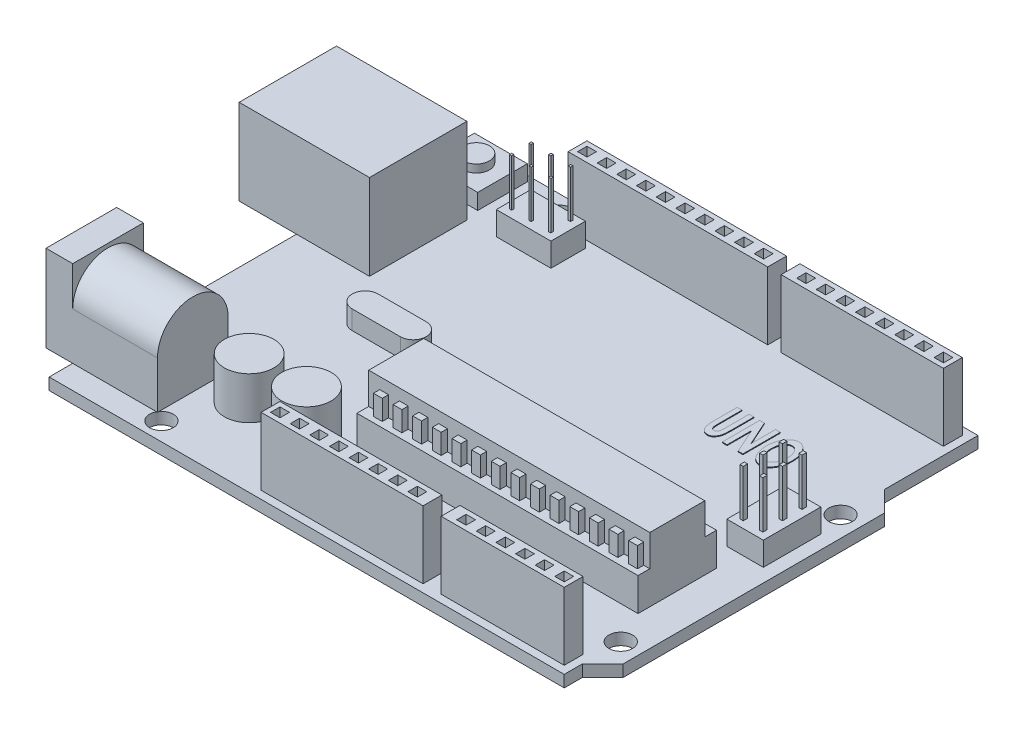
from build123d import *

# Parameters (mm, degrees)
SKETCH_1_R                  = 1.5
EXTRUDE_1_DEPTH             = 1.5
SKETCH_2_W                  = 16.6
SKETCH_2_H                  = 12.4
EXTRUDE_2_DEPTH             = 10.9
SKETCH_3_W                  = 4.372856204
SKETCH_3_H                  = 2.036672752
CUT_EXTRUDE_1_DEPTH         = 10.9
SKETCH_4_W                  = 6.743789425
SKETCH_4_H                  = 6.323115379
EXTRUDE_3_DEPTH             = 2
SKETCH_5_R                  = 1.664601264
EXTRUDE_4_DEPTH             = 1
SKETCH_6_W                  = 47.8
SKETCH_6_H                  = 2.4
SKETCH_6_W_2                = 38.6
EXTRUDE_5_DEPTH             = 8.6
SKETCH_7_W                  = 35.8
SKETCH_7_H                  = 10
EXTRUDE_6_DEPTH             = 8.2
SKETCH_8_R                  = 3.15
EXTRUDE_7_DEPTH             = 5.4
SKETCH_9_W                  = 1.2
SKETCH_9_H                  = 1.2
CUT_EXTRUDE_2_DEPTH         = 5.4
PATTERN_LINEAR_1_COUNT      = 8
PATTERN_LINEAR_1_PITCH      = 2.5
SKETCH_10_W                 = 1.2
SKETCH_10_H                 = 1.2
CUT_EXTRUDE_3_DEPTH         = 5.4
PATTERN_LINEAR_2_COUNT      = 10
PATTERN_LINEAR_2_PITCH      = 2.5
SKETCH_11_W                 = 1.2
SKETCH_11_H                 = 1.2
CUT_EXTRUDE_4_DEPTH         = 5.4
PATTERN_LINEAR_3_COUNT      = 6
PATTERN_LINEAR_3_PITCH      = 2.5
SKETCH_12_W                 = 1.2
SKETCH_12_H                 = 1.2
CUT_EXTRUDE_5_DEPTH         = 5.4
PATTERN_LINEAR_4_COUNT      = 8
PATTERN_LINEAR_4_PITCH      = 2.5
SKETCH_13_W                 = 9
SKETCH_13_H                 = 11
EXTRUDE_8_DEPTH             = 3.4
EXTRUDE_9_DEPTH             = 10.8
SKETCH_15_R                 = 3.884486149
SKETCH_15_R_2               = 0.407550436
CUT_EXTRUDE_6_DEPTH         = 10.8
SKETCH_16_W                 = 35.8
SKETCH_16_H                 = 1.5
CUT_EXTRUDE_7_DEPTH         = 4
SKETCH_17_W                 = 1.118511392
SKETCH_17_H                 = 2.561041253
EXTRUDE_10_DEPTH            = 0.8
PATTERN_LINEAR_5_COUNT      = 14
PATTERN_LINEAR_5_PITCH      = 2.5
SKETCH_18_W                 = 1.118511392
SKETCH_18_H                 = 2.561041253
EXTRUDE_11_DEPTH            = 0.8
PATTERN_LINEAR_6_COUNT      = 14
PATTERN_LINEAR_6_PITCH      = 2.5
SKETCH_19_W                 = 2.303918371
SKETCH_19_H                 = 2.4
SKETCH_19_W_2               = 1.705404008
CUT_EXTRUDE_8_DEPTH         = 8.6
SKETCH_20_W                 = 4.649103818
SKETCH_20_H                 = 7.318508938
SKETCH_20_W_2               = 6.955258845
SKETCH_20_H_2               = 4.390904447
EXTRUDE_12_DEPTH            = 3
SKETCH_21_W                 = 0.417659477
SKETCH_21_H                 = 0.556879301
EXTRUDE_13_DEPTH            = 6
PATTERN_LINEAR_7_COUNT      = 2
PATTERN_LINEAR_7_PITCH      = 2.5
PATTERN_LINEAR_7_COUNT_DIR2 = 3
PATTERN_LINEAR_7_PITCH_DIR2 = 2.5
SKETCH_22_W                 = 0.286309363
SKETCH_22_H                 = 0.308333161
EXTRUDE_14_DEPTH            = 6
PATTERN_LINEAR_8_COUNT      = 3
PATTERN_LINEAR_8_PITCH      = 2.5
PATTERN_LINEAR_8_COUNT_DIR2 = 2
PATTERN_LINEAR_8_PITCH_DIR2 = 2.5
CUT_EXTRUDE_9_DEPTH         = 3
EXTRUDE_15_DEPTH            = 0.1


with BuildPart() as part:
    # 草圖1 → 填料-伸長1 (new body)
    with BuildSketch(Plane(origin=(0, 0, 0), x_dir=(1, 0, 0), z_dir=(0, 1, 0))):
        Polygon((25.264109575, 24.624375052), (27.864109575, 22.024375052), (27.864109575, -11.275624948), (25.264109575, -13.875624948), (25.264109575, -16.175624948), (-40.335890425, -16.175624948), (-40.335890425, 36.524375052), (25.264109575, 36.524375052), align=None)
        with Locations((25.264109575, 19.024375052)):
            Circle(SKETCH_1_R, mode=Mode.SUBTRACT)
        with Locations((25.264109575, -8.975624948)):
            Circle(SKETCH_1_R, mode=Mode.SUBTRACT)
        with Locations((-25.735890425, 34.224375052)):
            Circle(SKETCH_1_R, mode=Mode.SUBTRACT)
        with Locations((-28.335890425, -13.875624948)):
            Circle(SKETCH_1_R, mode=Mode.SUBTRACT)
    extrude(amount=EXTRUDE_1_DEPTH)

    # 草圖2 → 填料-伸長2 (add)
    with BuildSketch(Plane(origin=(0, 1.5, 0), x_dir=(1, 0, 0), z_dir=(0, 1, 0))):
        with Locations((-39.335890425, 21.524375052)):
            Rectangle(SKETCH_2_W, SKETCH_2_H)
    extrude(amount=EXTRUDE_2_DEPTH)

    # 草圖3 → 除料-伸長1 (cut)
    with BuildSketch(Plane.ZY.offset(47.635890425)):
        Polygon((-24.401133252, 11.321632952), (-18.650527832, 11.321632952), (-16.40419759, 9.07530271), (-16.40419759, 2.815529102), (-26.677414564, 2.815529102), (-26.677414564, 9.07530271), align=None)
        with Locations((-21.555781612, 7.308189586)):
            Rectangle(SKETCH_3_W, SKETCH_3_H, mode=Mode.SUBTRACT)
    extrude(amount=-CUT_EXTRUDE_1_DEPTH, mode=Mode.SUBTRACT)

    # 草圖4 → 填料-伸長3 (add)
    with BuildSketch(Plane(origin=(0, 1.5, 0), x_dir=(1, 0, 0), z_dir=(0, 1, 0))):
        with Locations((-34.776113962, 32.636854406)):
            Rectangle(SKETCH_4_W, SKETCH_4_H)
    extrude(amount=EXTRUDE_3_DEPTH)

    # 草圖5 → 填料-伸長4 (add)
    with BuildSketch(Plane(origin=(0, 3.5, 0), x_dir=(1, 0, 0), z_dir=(0, 1, 0))):
        with Locations((-34.79753275, 32.69490015)):
            Circle(SKETCH_5_R)
    extrude(amount=EXTRUDE_4_DEPTH)

    # 草圖6 → 填料-伸長5 (add)
    with BuildSketch(Plane(origin=(0, 1.5, 0), x_dir=(1, 0, 0), z_dir=(0, 1, 0))):
        with Locations((0.364109575, 34.324375052)):
            Rectangle(SKETCH_6_W, SKETCH_6_H)
        with Locations((4.964109575, -13.975624948)):
            Rectangle(SKETCH_6_W_2, SKETCH_6_H)
    extrude(amount=EXTRUDE_5_DEPTH)

    # 草圖7 → 填料-伸長6 (add)
    with BuildSketch(Plane(origin=(0, 1.5, 0), x_dir=(1, 0, 0), z_dir=(0, 1, 0))):
        with Locations((5.364109575, 0.224375052)):
            Rectangle(SKETCH_7_W, SKETCH_7_H)
    extrude(amount=EXTRUDE_6_DEPTH)

    # 草圖8 → 填料-伸長7 (add)
    with BuildSketch(Plane(origin=(0, 1.5, 0), x_dir=(1, 0, 0), z_dir=(0, 1, 0))):
        with Locations((-24.77532315, -6.259782682)):
            Circle(SKETCH_8_R)
        with Locations((-17.480788386, -6.259782682)):
            Circle(SKETCH_8_R)
        with BuildLine():
            Line((-26.143940418, 11.529212552), (-20.017718682, 11.529212552))
            ThreePointArc((-20.017718682, 11.529212552), (-18.368351291, 9.879845161), (-20.017718682, 8.230477771))
            Line((-20.017718682, 8.230477771), (-26.143940418, 8.230477771))
            ThreePointArc((-26.143940418, 8.230477771), (-27.793307808, 9.879845161), (-26.143940418, 11.529212552))
        make_face()
    extrude(amount=EXTRUDE_7_DEPTH)

    # 草圖9 → 除料-伸長2 (cut)
    with BuildSketch(Plane(origin=(0, 10.1, 0), x_dir=(1, 0, 0), z_dir=(0, 1, 0))):
        with Locations((23.064109575, 34.324375052)):
            Rectangle(SKETCH_9_W, SKETCH_9_H)
    cut_extrude_2 = extrude(amount=-CUT_EXTRUDE_2_DEPTH, mode=Mode.SUBTRACT)

    # 直線複製排列1: 除料-伸長2 ×8
    with Locations(*[(-i * PATTERN_LINEAR_1_PITCH, 0, 0) for i in range(1, PATTERN_LINEAR_1_COUNT)]):
        add(cut_extrude_2, mode=Mode.SUBTRACT)

    # 草圖10 → 除料-伸長3 (cut)
    with BuildSketch(Plane(origin=(0, 10.1, 0), x_dir=(1, 0, 0), z_dir=(0, 1, 0))):
        with Locations((-22.335890425, 34.324375052)):
            Rectangle(SKETCH_10_W, SKETCH_10_H)
    cut_extrude_3 = extrude(amount=-CUT_EXTRUDE_3_DEPTH, mode=Mode.SUBTRACT)

    # 直線複製排列2: 除料-伸長3 ×10
    with Locations(*[(i * PATTERN_LINEAR_2_PITCH, 0, 0) for i in range(1, PATTERN_LINEAR_2_COUNT)]):
        add(cut_extrude_3, mode=Mode.SUBTRACT)

    # 草圖11 → 除料-伸長4 (cut)
    with BuildSketch(Plane(origin=(0, 10.1, 0), x_dir=(1, 0, 0), z_dir=(0, 1, 0))):
        with Locations((23.064109575, -13.975624948)):
            Rectangle(SKETCH_11_W, SKETCH_11_H)
    cut_extrude_4 = extrude(amount=-CUT_EXTRUDE_4_DEPTH, mode=Mode.SUBTRACT)

    # 直線複製排列3: 除料-伸長4 ×6
    with Locations(*[(-i * PATTERN_LINEAR_3_PITCH, 0, 0) for i in range(1, PATTERN_LINEAR_3_COUNT)]):
        add(cut_extrude_4, mode=Mode.SUBTRACT)

    # 草圖12 → 除料-伸長5 (cut)
    with BuildSketch(Plane(origin=(0, 10.1, 0), x_dir=(1, 0, 0), z_dir=(0, 1, 0))):
        with Locations((-13.135890425, -13.975624948)):
            Rectangle(SKETCH_12_W, SKETCH_12_H)
    cut_extrude_5 = extrude(amount=-CUT_EXTRUDE_5_DEPTH, mode=Mode.SUBTRACT)

    # 直線複製排列4: 除料-伸長5 ×8
    with Locations(*[(i * PATTERN_LINEAR_4_PITCH, 0, 0) for i in range(1, PATTERN_LINEAR_4_COUNT)]):
        add(cut_extrude_5, mode=Mode.SUBTRACT)



with BuildPart() as body_2:
    # 草圖13 → 填料-伸長8 (new body)
    with BuildSketch(Plane.ZY.offset(40.335890425)):
        with Locations((8.675624948, 7)):
            Rectangle(SKETCH_13_W, SKETCH_13_H)
    extrude(amount=EXTRUDE_8_DEPTH)


with BuildPart() as part_1:
    add(part.part)

    add(body_2.part)  # 填料-伸長9 merges body 2
    # 草圖14 → 填料-伸長9 (add)
    with BuildSketch(Plane(origin=(-40.335890425, 0, 0), x_dir=(0, 0, -1), z_dir=(1, 0, 0))):
        with BuildLine():
            Line((-13.175624948, 7.5), (-13.175624948, 1.5))
            Line((-13.175624948, 1.5), (-4.175624948, 1.5))
            Line((-4.175624948, 1.5), (-4.175624948, 7.5))
            ThreePointArc((-4.175624948, 7.5), (-8.675624948, 12), (-13.175624948, 7.5))
        make_face()
    extrude(amount=EXTRUDE_9_DEPTH)

    # 草圖15 → 除料-伸長6 (cut)
    with BuildSketch(Plane.ZY.offset(43.735890425)):
        with Locations((8.675624948, 7.5)):
            Circle(SKETCH_15_R)
        with Locations((8.675624948, 7.5)):
            Circle(SKETCH_15_R_2, mode=Mode.SUBTRACT)
    extrude(amount=-CUT_EXTRUDE_6_DEPTH, mode=Mode.SUBTRACT)

    # 草圖16 → 除料-伸長7 (cut)
    with BuildSketch(Plane(origin=(0, 9.7, 0), x_dir=(1, 0, 0), z_dir=(0, 1, 0))):
        with Locations((5.364109575, 4.474375052)):
            Rectangle(SKETCH_16_W, SKETCH_16_H)
        with Locations((5.364109575, -4.025624948)):
            Rectangle(SKETCH_16_W, SKETCH_16_H)
    extrude(amount=-CUT_EXTRUDE_7_DEPTH, mode=Mode.SUBTRACT)

    # 草圖17 → 填料-伸長10 (add)
    with BuildSketch(Plane.XY.offset(3.275624948)):
        with Locations((21.932327047, 6.980520627)):
            Rectangle(SKETCH_17_W, SKETCH_17_H)
    extrude_10 = extrude(amount=EXTRUDE_10_DEPTH)

    # 直線複製排列5: 填料-伸長10 ×14
    with Locations(*[(-i * PATTERN_LINEAR_5_PITCH, 0, 0) for i in range(1, PATTERN_LINEAR_5_COUNT)]):
        add(extrude_10)

    # 草圖18 → 填料-伸長11 (add)
    with BuildSketch(Plane(origin=(0, 0, -3.724375052), x_dir=(-1, 0, 0), z_dir=(0, 0, -1))):
        with Locations((-21.932327047, 6.980520627)):
            Rectangle(SKETCH_18_W, SKETCH_18_H)
    extrude_11 = extrude(amount=EXTRUDE_11_DEPTH)

    # 直線複製排列6: 填料-伸長11 ×14
    with Locations(*[(-i * PATTERN_LINEAR_6_PITCH, 0, 0) for i in range(1, PATTERN_LINEAR_6_COUNT)]):
        add(extrude_11)

    # 草圖19 → 除料-伸長8 (cut)
    with BuildSketch(Plane(origin=(0, 10.1, 0), x_dir=(1, 0, 0), z_dir=(0, 1, 0))):
        with Locations((7.438966634, -13.975624948)):
            Rectangle(SKETCH_19_W, SKETCH_19_H)
        with Locations((2.735612575, 34.324375052)):
            Rectangle(SKETCH_19_W_2, SKETCH_19_H)
    extrude(amount=-CUT_EXTRUDE_8_DEPTH, mode=Mode.SUBTRACT)

    # 草圖20 → 填料-伸長12 (add)
    with BuildSketch(Plane(origin=(0, 1.5, 0), x_dir=(1, 0, 0), z_dir=(0, 1, 0))):
        with Locations((23.817810793, 11.962861826)):
            Rectangle(SKETCH_20_W, SKETCH_20_H)
        with Locations((-23.848148774, 29.960907714)):
            Rectangle(SKETCH_20_W_2, SKETCH_20_H_2)
    extrude(amount=EXTRUDE_12_DEPTH)

    # 草圖21 → 填料-伸長13 (add)
    with BuildSketch(Plane(origin=(0, 4.5, 0), x_dir=(1, 0, 0), z_dir=(0, 1, 0))):
        with Locations((22.519293067, 14.436792221)):
            Rectangle(SKETCH_21_W, SKETCH_21_H)
    extrude_13 = extrude(amount=EXTRUDE_13_DEPTH)

    # 直線複製排列7: Extrude 13 2 × 3
    with Locations(*[(i * PATTERN_LINEAR_7_PITCH, 0, j * PATTERN_LINEAR_7_PITCH_DIR2) for i in range(PATTERN_LINEAR_7_COUNT) for j in range(PATTERN_LINEAR_7_COUNT_DIR2) if (i, j) != (0, 0)]):
        add(extrude_13)

    # 草圖22 → 填料-伸長14 (add)
    with BuildSketch(Plane(origin=(0, 4.5, 0), x_dir=(1, 0, 0), z_dir=(0, 1, 0))):
        with Locations((-26.416051687, 31.311286842)):
            Rectangle(SKETCH_22_W, SKETCH_22_H)
    extrude_14 = extrude(amount=EXTRUDE_14_DEPTH)

    # 直線複製排列8: Extrude 14 3 × 2
    with Locations(*[(i * PATTERN_LINEAR_8_PITCH, 0, j * PATTERN_LINEAR_8_PITCH_DIR2) for i in range(PATTERN_LINEAR_8_COUNT) for j in range(PATTERN_LINEAR_8_COUNT_DIR2) if (i, j) != (0, 0)]):
        add(extrude_14)

    # 草圖23 → 除料-伸長9 (cut)
    with BuildSketch(Plane(origin=(0, 6.9, 0), x_dir=(1, 0, 0), z_dir=(0, 1, 0))):
        with BuildLine():
            Line((-26.143940418, 8.230477771), (-20.017718682, 8.230477771))
            ThreePointArc((-20.017718682, 8.230477771), (-18.368351291, 9.879845161), (-20.017718682, 11.529212552))
            Line((-20.017718682, 11.529212552), (-26.143940418, 11.529212552))
            ThreePointArc((-26.143940418, 11.529212552), (-27.793307808, 9.879845161), (-26.143940418, 8.230477771))
        make_face()
    extrude(amount=-CUT_EXTRUDE_9_DEPTH, mode=Mode.SUBTRACT)

    # 草圖24 → 填料-伸長15 (add)
    with BuildSketch(Plane(origin=(0, 1.5, 0), x_dir=(1, 0, 0), z_dir=(0, 1, 0))):
        with BuildLine():
            Line((6.929364367, 24.183976571), (7.53994129, 24.183976571))
            Line((7.53994129, 24.183976571), (7.53994129, 21.085298686))
            add(Edge.make_bspline(
                [(7.53994129, 21.085298686), (7.540212832, 21.053179907), (7.540737142, 20.991163103), (7.542236694, 20.902085271), (7.54631885, 20.820361201), (7.551047503, 20.745936499), (7.556397096, 20.678429693), (7.563829256, 20.618222496), (7.573445028, 20.565751752), (7.587022084, 20.506270758), (7.609234319, 20.440769504), (7.643149052, 20.369633363), (7.683676575, 20.306347721), (7.732607568, 20.252352033), (7.788223756, 20.209265096), (7.849127481, 20.17649563), (7.91671419, 20.15825717), (7.9634262, 20.155554687), (7.987379692, 20.154168879)],
                knots=[0, 0, 0, 0, 9.6361e-05, 0.00018606, 0.000267242, 0.000341809, 0.000409786, 0.000470373, 0.000523704, 0.000569755, 0.000653324, 0.000730559, 0.000805709, 0.00087797, 0.000948005, 0.001015855, 0.001084133, 0.001155996, 0.001155996, 0.001155996, 0.001155996], degree=3))
            add(Edge.make_bspline(
                [(7.987379692, 20.154168879), (8.012656647, 20.155330675), (8.062538557, 20.157623382), (8.133983456, 20.179506667), (8.19979037, 20.214822697), (8.258402447, 20.263767779), (8.309524812, 20.323394916), (8.353787927, 20.390106015), (8.388538811, 20.465091142), (8.409666588, 20.534071503), (8.423672858, 20.596809003), (8.431644476, 20.654280982), (8.439307807, 20.721393893), (8.445946284, 20.798047858), (8.450658178, 20.884586495), (8.453131482, 20.980662911), (8.455129224, 21.086562971), (8.45557447, 21.160347661), (8.455806675, 21.198827833)],
                knots=[0, 0, 0, 0, 7.5663e-05, 0.000149315, 0.000221878, 0.000298468, 0.000376907, 0.000456818, 0.00053791, 0.000623905, 0.000672747, 0.000730629, 0.000797845, 0.000875409, 0.000961404, 0.001057803, 0.001163718, 0.001279159, 0.001279159, 0.001279159, 0.001279159], degree=3))
            Line((8.455806675, 21.198827833), (8.455806675, 24.183976571))
            Line((8.455806675, 24.183976571), (9.066383598, 24.183976571))
            Line((9.066383598, 24.183976571), (9.066383598, 21.342885826))
            add(Edge.make_bspline(
                [(9.066383598, 21.342885826), (9.066081425, 21.285327313), (9.065500436, 21.17465933), (9.064413182, 21.015612255), (9.058924963, 20.870307315), (9.053930228, 20.738902301), (9.045777244, 20.621277611), (9.038169871, 20.517098588), (9.02640889, 20.426820377), (9.010232741, 20.324495218), (8.982780201, 20.206605657), (8.936025842, 20.07079722), (8.879087987, 19.936760111), (8.81004134, 19.808084192), (8.73358336, 19.687642173), (8.648572454, 19.58256972), (8.558602522, 19.492899328), (8.46115621, 19.421851613), (8.357494056, 19.365692275), (8.245069082, 19.32823282), (8.125233049, 19.303132304), (8.042210963, 19.30063662), (7.999782036, 19.299361186)],
                knots=[0, 0, 0, 0, 0.000172681, 0.000332015, 0.000477106, 0.000608886, 0.000726479, 0.000830822, 0.000922174, 0.000999498, 0.001141584, 0.001284586, 0.001429899, 0.001577997, 0.001722219, 0.00185721, 0.001982693, 0.002102144, 0.002217806, 0.002334868, 0.002456483, 0.002583597, 0.002583597, 0.002583597, 0.002583597], degree=3))
            add(Edge.make_bspline(
                [(7.999782036, 19.299361186), (7.971432108, 19.300030702), (7.915765491, 19.301345333), (7.833814357, 19.313661126), (7.754435053, 19.331277421), (7.677730271, 19.357281102), (7.603912249, 19.390843802), (7.532975319, 19.432093749), (7.465286564, 19.481080407), (7.378490022, 19.555215866), (7.280425281, 19.661128603), (7.180147286, 19.804198508), (7.097705829, 19.961915736), (7.044032267, 20.106221037), (7.010098577, 20.234773103), (6.988616986, 20.347652504), (6.970902353, 20.47602738), (6.955980397, 20.619549938), (6.943420534, 20.778580886), (6.935145424, 20.952930331), (6.930616292, 21.14283381), (6.929792254, 21.274511457), (6.929364367, 21.342885826)],
                knots=[0, 0, 0, 0, 8.4994e-05, 0.00016689, 0.000248123, 0.000328675, 0.000409367, 0.000491019, 0.000574418, 0.000659685, 0.000833163, 0.001005734, 0.001182402, 0.001365637, 0.001466299, 0.001580993, 0.001710111, 0.001854975, 0.002013829, 0.002188626, 0.002378538, 0.002583662, 0.002583662, 0.002583662, 0.002583662], degree=3))
            Line((6.929364367, 21.342885826), (6.929364367, 24.183976571))
        make_face()
        Polygon((9.799075906, 24.183976571), (10.396296459, 24.183976571), (11.813979752, 21.049999708), (11.813979752, 24.183976571), (12.424556675, 24.183976571), (12.424556675, 19.421476571), (11.823520016, 19.421476571), (10.409652829, 22.54591317), (10.409652829, 19.421476571), (9.799075906, 19.421476571), align=None)
        with BuildLine():
            add(Edge.make_bspline(
                [(14.690369475, 24.306091956), (14.745567652, 24.303938871), (14.855142947, 24.299664727), (15.016170422, 24.263784245), (15.171236792, 24.206050957), (15.320221621, 24.125058793), (15.462322904, 24.020117599), (15.599160913, 23.893629272), (15.728957513, 23.743220044), (15.851368536, 23.572802989), (15.964278975, 23.386459182), (16.062158111, 23.187220588), (16.146914432, 22.979053781), (16.214045946, 22.760124716), (16.268227564, 22.531776685), (16.304193378, 22.292722156), (16.328190112, 22.043949032), (16.330879163, 21.874655433), (16.332248983, 21.788416174)],
                knots=[0, 0, 0, 0, 0.000165443, 0.000328425, 0.000492343, 0.000660536, 0.000835329, 0.001020992, 0.001218436, 0.001430264, 0.001649835, 0.00187127, 0.002095554, 0.002323374, 0.002557562, 0.002798953, 0.003048055, 0.003306709, 0.003306709, 0.003306709, 0.003306709], degree=3))
            add(Edge.make_bspline(
                [(16.332248983, 21.788416174), (16.330742587, 21.703144499), (16.3277809, 21.535494072), (16.305672869, 21.289090245), (16.268607245, 21.052552104), (16.216459143, 20.826011215), (16.148187745, 20.609696891), (16.066647398, 20.402858515), (15.968434197, 20.206785787), (15.858572257, 20.021922508), (15.73619205, 19.8545394), (15.607808758, 19.705998351), (15.471441075, 19.581261858), (15.329568235, 19.47719453), (15.179719719, 19.397511457), (15.02345023, 19.340450721), (14.860728297, 19.30606293), (14.74999942, 19.301607157), (14.694185581, 19.299361186)],
                knots=[0, 0, 0, 0, 0.000255793, 0.000502908, 0.000741472, 0.000973585, 0.001199584, 0.001421387, 0.001639834, 0.001856786, 0.002065738, 0.002261117, 0.002444787, 0.002619019, 0.002787601, 0.002952084, 0.003116736, 0.003284082, 0.003284082, 0.003284082, 0.003284082], degree=3))
            add(Edge.make_bspline(
                [(14.694185581, 19.299361186), (14.635781778, 19.301358415), (14.520415007, 19.305303601), (14.351873941, 19.342967705), (14.189669578, 19.399119283), (14.037219212, 19.483731998), (13.890693896, 19.587798278), (13.754134722, 19.717927484), (13.624041163, 19.869373638), (13.50346629, 20.042088609), (13.394269686, 20.230457118), (13.297150383, 20.429437654), (13.216395245, 20.637657528), (13.150293026, 20.854547749), (13.099145379, 21.079709989), (13.061694477, 21.313556279), (13.039638772, 21.556161388), (13.036650858, 21.720953387), (13.035133598, 21.804634624)],
                knots=[0, 0, 0, 0, 0.000174962, 0.000345607, 0.000515799, 0.000688256, 0.0008667, 0.001053662, 0.001252549, 0.001464823, 0.001684575, 0.001905169, 0.002128397, 0.002353832, 0.002584801, 0.002820539, 0.003063853, 0.003314878, 0.003314878, 0.003314878, 0.003314878], degree=3))
            add(Edge.make_bspline(
                [(13.035133598, 21.804634624), (13.036027394, 21.860933055), (13.037801062, 21.972652881), (13.047080434, 22.138542102), (13.064076135, 22.300958925), (13.089526893, 22.459601779), (13.119585259, 22.615077923), (13.156792068, 22.767373128), (13.201673225, 22.915989147), (13.253298187, 23.060700152), (13.30962398, 23.200264669), (13.373019493, 23.332648257), (13.441791983, 23.457120265), (13.513982394, 23.575340025), (13.592774457, 23.685330031), (13.676158496, 23.788322467), (13.765675781, 23.883077051), (13.858706676, 23.970729394), (13.955123776, 24.049930881), (14.055233744, 24.117641201), (14.155996575, 24.176773862), (14.259765187, 24.222892758), (14.364204667, 24.261565558), (14.471368117, 24.286177691), (14.5800623, 24.30399605), (14.653405571, 24.305389618), (14.690369475, 24.306091956)],
                knots=[0, 0, 0, 0, 0.000168906, 0.00033518, 0.000498271, 0.000658571, 0.000817045, 0.000973232, 0.001128668, 0.001282559, 0.001434033, 0.001579971, 0.001722582, 0.00186052, 0.001995268, 0.002128175, 0.002257762, 0.002385999, 0.002511456, 0.002631592, 0.002748268, 0.002861412, 0.002971857, 0.003081769, 0.003190787, 0.003301557, 0.003301557, 0.003301557, 0.003301557], degree=3))
        make_face()
        with BuildLine():
            add(Edge.make_bspline(
                [(14.681783237, 23.451284263), (14.645730578, 23.449799733), (14.574535755, 23.446868163), (14.470453182, 23.424019264), (14.370671963, 23.38757703), (14.275780183, 23.335007894), (14.184734916, 23.269087444), (14.099116111, 23.187418712), (14.018333481, 23.091307122), (13.941420919, 22.982499177), (13.872761116, 22.861643994), (13.811070941, 22.732469304), (13.760071675, 22.595014832), (13.717764283, 22.450000243), (13.685422606, 22.296899757), (13.663273524, 22.135867721), (13.64818871, 21.967103321), (13.646549319, 21.852052394), (13.645710521, 21.793186307)],
                knots=[0, 0, 0, 0, 0.000108075, 0.00021342, 0.000318159, 0.000425744, 0.00053776, 0.000654515, 0.000779725, 0.000913921, 0.001053672, 0.001196205, 0.001342927, 0.001492976, 0.001649029, 0.001811877, 0.001980395, 0.002156954, 0.002156954, 0.002156954, 0.002156954], degree=3))
            add(Edge.make_bspline(
                [(13.645710521, 21.793186307), (13.646630333, 21.727940467), (13.648428856, 21.600364294), (13.667635659, 21.41469842), (13.694726148, 21.238839411), (13.73793383, 21.074384615), (13.789131032, 20.919157819), (13.854909166, 20.775484299), (13.930607519, 20.641522759), (13.991442183, 20.560618141), (14.021596939, 20.520515033)],
                knots=[0, 0, 0, 0, 0.000195659, 0.000382575, 0.000559493, 0.000728869, 0.000892086, 0.001049208, 0.001202212, 0.001352598, 0.001352598, 0.001352598, 0.001352598], degree=3))
            add(Edge.make_bspline(
                [(14.021596939, 20.520515033), (14.045871269, 20.491414477), (14.093065212, 20.434837425), (14.17082142, 20.360108137), (14.251074228, 20.29688906), (14.333832412, 20.244258166), (14.419910689, 20.204240063), (14.508278375, 20.17538486), (14.599320286, 20.15730899), (14.661029147, 20.155224454), (14.692277528, 20.154168879)],
                knots=[0, 0, 0, 0, 0.000113621, 0.000220902, 0.000322817, 0.000419697, 0.000514448, 0.000606768, 0.000698075, 0.000791745, 0.000791745, 0.000791745, 0.000791745], degree=3))
            add(Edge.make_bspline(
                [(14.692277528, 20.154168879), (14.72736386, 20.155703062), (14.796956279, 20.158746057), (14.899132702, 20.181113198), (14.996679301, 20.219432762), (15.090894908, 20.270944532), (15.180238193, 20.339037091), (15.265140424, 20.421817753), (15.346291585, 20.518884245), (15.422889957, 20.629002385), (15.493078086, 20.750145825), (15.553387885, 20.880199963), (15.607035789, 21.016096398), (15.647943654, 21.159833023), (15.68229381, 21.309967361), (15.703944345, 21.467378928), (15.719208036, 21.631338081), (15.720839226, 21.742902985), (15.72167206, 21.799864492)],
                knots=[0, 0, 0, 0, 0.00010522, 0.0002087, 0.000311991, 0.000418739, 0.000529788, 0.00064786, 0.000773799, 0.000908776, 0.00104983, 0.001193226, 0.001338505, 0.001487639, 0.001641097, 0.001800168, 0.001963933, 0.002134771, 0.002134771, 0.002134771, 0.002134771], degree=3))
            add(Edge.make_bspline(
                [(15.72167206, 21.799864492), (15.720782934, 21.856499514), (15.719036706, 21.967729728), (15.704503944, 22.131220011), (15.680475031, 22.287886189), (15.648684218, 22.43833577), (15.605496698, 22.581770787), (15.552722383, 22.718341866), (15.492086119, 22.849135407), (15.420495888, 22.970499136), (15.34482324, 23.082980946), (15.26213246, 23.180640544), (15.176769655, 23.264632169), (15.085803757, 23.33245694), (14.990783273, 23.385279968), (14.891908717, 23.424353312), (14.788042302, 23.446753067), (14.717504224, 23.449761016), (14.681783237, 23.451284263)],
                knots=[0, 0, 0, 0, 0.000169884, 0.000333649, 0.000491916, 0.000645171, 0.000794576, 0.000940744, 0.00108414, 0.001226498, 0.001363044, 0.001490327, 0.001609748, 0.001721561, 0.001829606, 0.001935021, 0.002039433, 0.002146556, 0.002146556, 0.002146556, 0.002146556], degree=3))
        make_face(mode=Mode.SUBTRACT)
    extrude(amount=EXTRUDE_15_DEPTH)


solid = part_1.part
